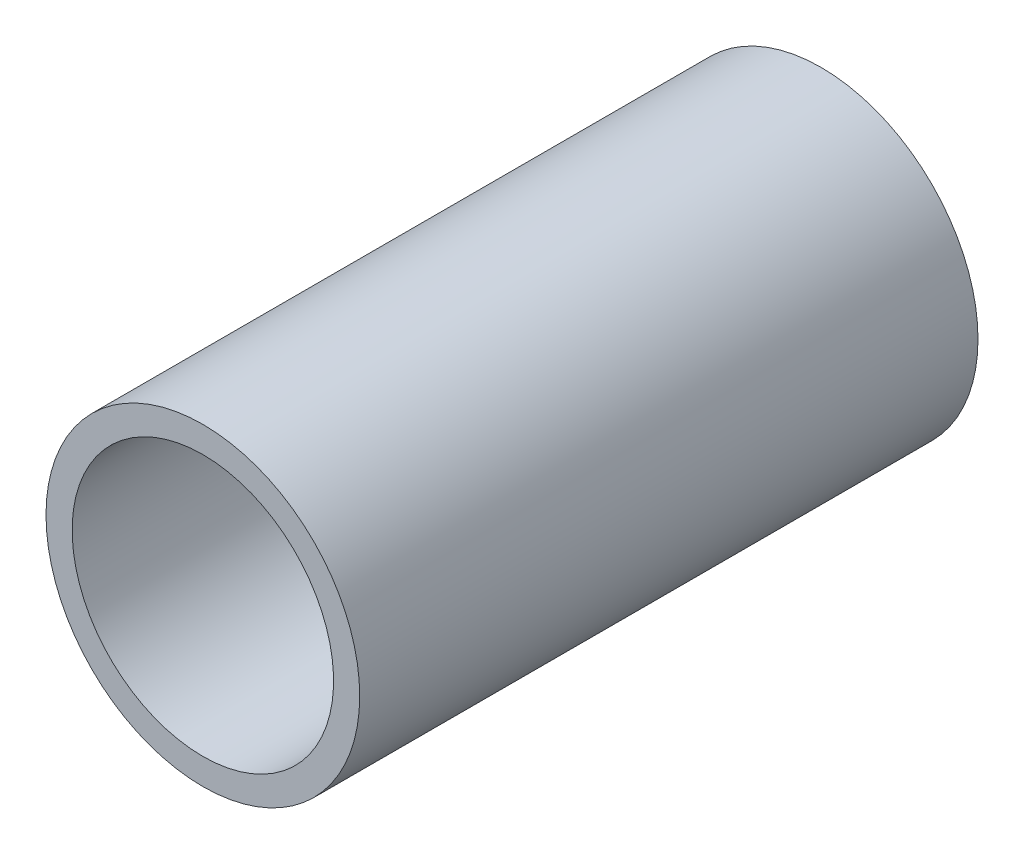
from build123d import *

# Parameters (mm, degrees)
SKETCH1_R           = 6
SKETCH1_R_2         = 5
BOSS_EXTRUDE1_DEPTH = 23.65


with BuildPart() as part:
    # Sketch1 → Boss-Extrude1 (new body)
    with BuildSketch(Plane.XY):
        Circle(SKETCH1_R)
        Circle(SKETCH1_R_2, mode=Mode.SUBTRACT)
    extrude(amount=BOSS_EXTRUDE1_DEPTH)


solid = part.part
